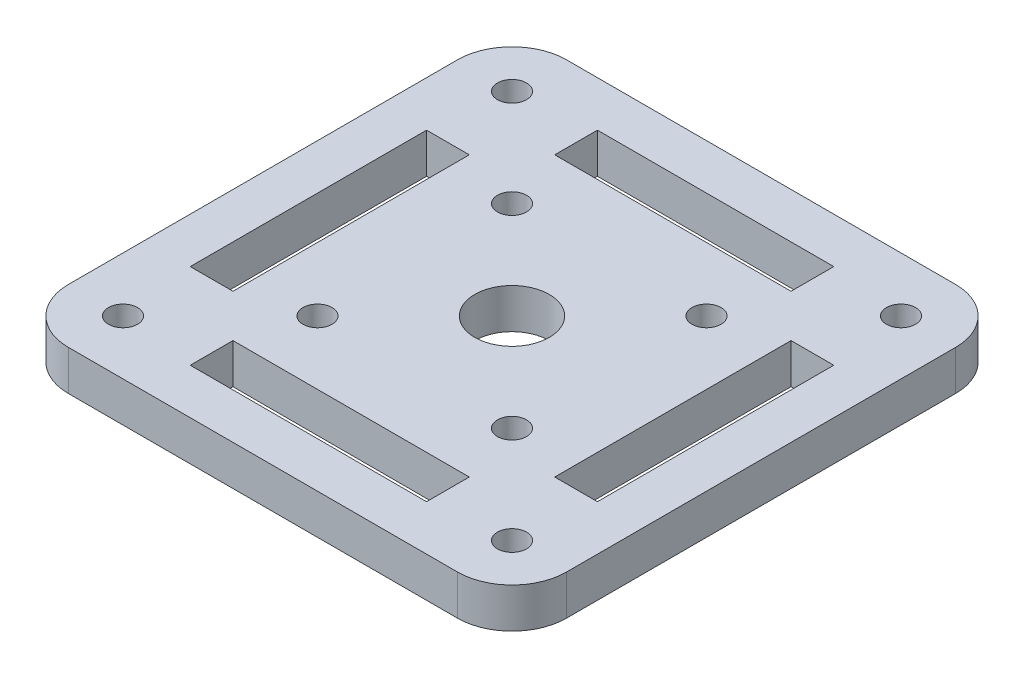
from build123d import *

# Parameters (mm, degrees)
SKETCH_1_W          = 54.8
SKETCH_1_H          = 54.8
SKETCH_1_R          = 4.1
SKETCH_1_R_2        = 1.6
EXTRUDE_1_DEPTH     = 4.4
FILLET_1_R          = 6
SKETCH_2_R          = 1.6
CUT_EXTRUDE_1_DEPTH = 10


with BuildPart() as part:
    # 草图1 → 凸台-拉伸1 (new body)
    with BuildSketch(Plane(origin=(0, 0, 0), x_dir=(1, 0, 0), z_dir=(0, 1, 0))):
        Rectangle(SKETCH_1_W, SKETCH_1_H)
        Circle(SKETCH_1_R, mode=Mode.SUBTRACT)
        with Locations((21.4, 21.4)):
            Circle(SKETCH_1_R_2, mode=Mode.SUBTRACT)
        with Locations((21.4, -21.4)):
            Circle(SKETCH_1_R_2, mode=Mode.SUBTRACT)
        with Locations((-21.4, -21.4)):
            Circle(SKETCH_1_R_2, mode=Mode.SUBTRACT)
        with Locations((-21.4, 21.4)):
            Circle(SKETCH_1_R_2, mode=Mode.SUBTRACT)
        Polygon((17.7, -5), (17.7, 5), (17.7, 13), (22.4, 13), (22.4, 5), (22.4, -5), (22.4, -13), (17.7, -13), align=None, mode=Mode.SUBTRACT)
        Polygon((-5, 17.7), (-13, 17.7), (-13, 22.4), (-5, 22.4), (5, 22.4), (13, 22.4), (13, 17.7), (5, 17.7), align=None, mode=Mode.SUBTRACT)
        Polygon((5, -17.7), (13, -17.7), (13, -22.4), (5, -22.4), (-5, -22.4), (-13, -22.4), (-13, -17.7), (-5, -17.7), align=None, mode=Mode.SUBTRACT)
        Polygon((-17.7, 5), (-17.7, -5), (-17.7, -13), (-22.4, -13), (-22.4, -5), (-22.4, 5), (-22.4, 13), (-17.7, 13), align=None, mode=Mode.SUBTRACT)
    extrude(amount=EXTRUDE_1_DEPTH)

    # 圆角1
    fillet_1_edges = [part.edges().sort_by_distance(p)[0] for p in [
        (27.4, 2.2, 27.4),
        (-27.4, 2.2, 27.4),
        (-27.4, 2.2, -27.4),
        (27.4, 2.2, -27.4),
    ]]
    fillet(fillet_1_edges, radius=FILLET_1_R)

    # 草图2 → 切除-拉伸1 (cut)
    with BuildSketch(Plane(origin=(0, 4.4, 0), x_dir=(1, 0, 0), z_dir=(0, 1, 0))):
        with Locations((10.7, 10.7)):
            Circle(SKETCH_2_R)
        with Locations((10.7, -10.7)):
            Circle(SKETCH_2_R)
        with Locations((-10.7, -10.7)):
            Circle(SKETCH_2_R)
        with Locations((-10.7, 10.7)):
            Circle(SKETCH_2_R)
    extrude(amount=-CUT_EXTRUDE_1_DEPTH, mode=Mode.SUBTRACT)


solid = part.part
